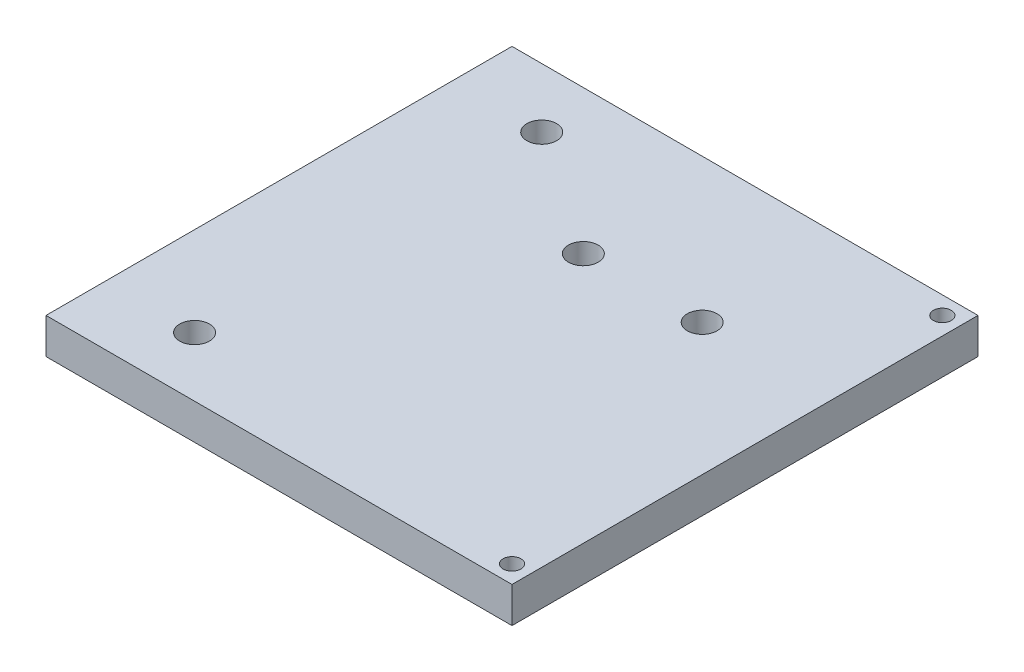
from build123d import *

# Parameters (mm, degrees)
SKETCH1_W           = 78.4
SKETCH1_H           = 78.4
SKETCH1_R           = 2.5
SKETCH1_R_2         = 1.5
BOSS_EXTRUDE1_DEPTH = 6


with BuildPart() as part:
    # Sketch1 → Boss-Extrude1 (new body)
    with BuildSketch(Plane(origin=(0, 0, 0), x_dir=(1, 0, 0), z_dir=(0, 1, 0))):
        Rectangle(SKETCH1_W, SKETCH1_H)
        with Locations((-24.2, 29.2)):
            Circle(SKETCH1_R, mode=Mode.SUBTRACT)
        with Locations((-24.2, -29.2)):
            Circle(SKETCH1_R, mode=Mode.SUBTRACT)
        with Locations((36.2, 36.2)):
            Circle(SKETCH1_R_2, mode=Mode.SUBTRACT)
        with Locations((36.2, -36.2)):
            Circle(SKETCH1_R_2, mode=Mode.SUBTRACT)
        with Locations((-3, 15)):
            Circle(SKETCH1_R, mode=Mode.SUBTRACT)
        with Locations((17, 15)):
            Circle(SKETCH1_R, mode=Mode.SUBTRACT)
    extrude(amount=BOSS_EXTRUDE1_DEPTH)


solid = part.part
